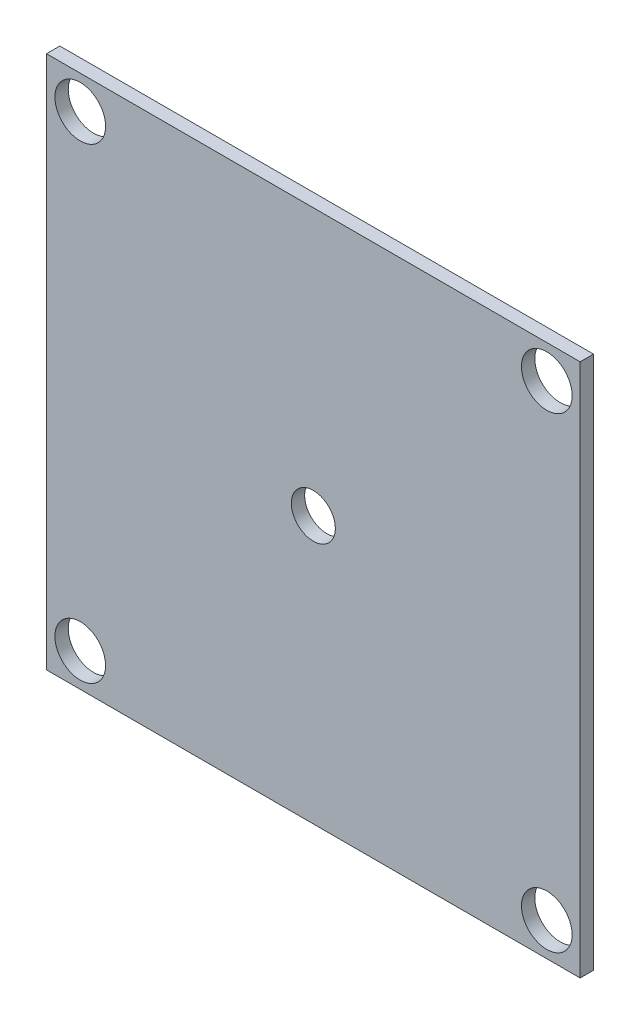
from build123d import *

# Parameters (mm, degrees)
SKETCH1_W           = 101.6
SKETCH1_H           = 101.6
BOSS_EXTRUDE1_DEPTH = 2.54
SKETCH3_R           = 4.191
CUT_EXTRUDE1_DEPTH  = 635
SKETCH2_R           = 4.826
CUT_EXTRUDE6_DEPTH  = 2.54


with BuildPart() as part:
    # Sketch1 → Boss-Extrude1 (new body)
    with BuildSketch(Plane.XY):
        Rectangle(SKETCH1_W, SKETCH1_H)
    extrude(amount=BOSS_EXTRUDE1_DEPTH)

    # Sketch3 → Cut-Extrude1 (cut)
    with BuildSketch(Plane.XY.offset(2.54)):
        Circle(SKETCH3_R)
    extrude(amount=-CUT_EXTRUDE1_DEPTH, mode=Mode.SUBTRACT)

    # Sketch2 → Cut-Extrude6 (cut)
    with BuildSketch(Plane(origin=(0, 0, 0), x_dir=(-1, 0, 0), z_dir=(0, 0, -1))):
        with Locations((-44.45, 44.45)):
            Circle(SKETCH2_R)
        with Locations((44.377290972, 44.45)):
            Circle(SKETCH2_R)
        with Locations((44.377290972, -44.45)):
            Circle(SKETCH2_R)
        with Locations((-44.45, -44.45)):
            Circle(SKETCH2_R)
    extrude(amount=-CUT_EXTRUDE6_DEPTH, mode=Mode.SUBTRACT)


solid = part.part
